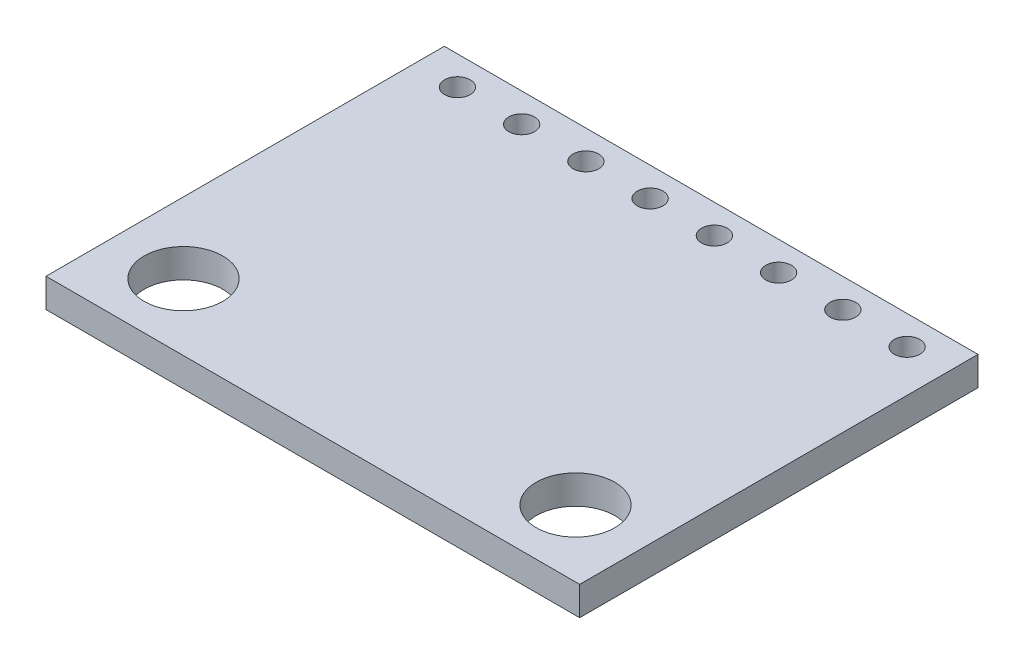
from build123d import *

# Parameters (mm, degrees)
SKETCH1_W           = 21.1
SKETCH1_H           = 15.748
SKETCH1_R           = 1.55575
SKETCH1_R_2         = 0.508
BOSS_EXTRUDE1_DEPTH = 0.5715


with BuildPart() as part:
    # Sketch1 → Boss-Extrude1 (new body, symmetric)
    with BuildSketch(Plane(origin=(0, 0, 0), x_dir=(1, 0, 0), z_dir=(0, 1, 0))):
        Rectangle(SKETCH1_W, SKETCH1_H)
        with Locations((-7.75, -5.23875)):
            Circle(SKETCH1_R, mode=Mode.SUBTRACT)
        with Locations((7.75, -5.23875)):
            Circle(SKETCH1_R, mode=Mode.SUBTRACT)
        with Locations((-8.89, 6.731)):
            Circle(SKETCH1_R_2, mode=Mode.SUBTRACT)
        with Locations((-6.35, 6.731)):
            Circle(SKETCH1_R_2, mode=Mode.SUBTRACT)
        with Locations((-3.81, 6.731)):
            Circle(SKETCH1_R_2, mode=Mode.SUBTRACT)
        with Locations((-1.27, 6.731)):
            Circle(SKETCH1_R_2, mode=Mode.SUBTRACT)
        with Locations((1.27, 6.731)):
            Circle(SKETCH1_R_2, mode=Mode.SUBTRACT)
        with Locations((3.81, 6.731)):
            Circle(SKETCH1_R_2, mode=Mode.SUBTRACT)
        with Locations((6.35, 6.731)):
            Circle(SKETCH1_R_2, mode=Mode.SUBTRACT)
        with Locations((8.89, 6.731)):
            Circle(SKETCH1_R_2, mode=Mode.SUBTRACT)
    extrude(amount=BOSS_EXTRUDE1_DEPTH, both=True)


solid = part.part
